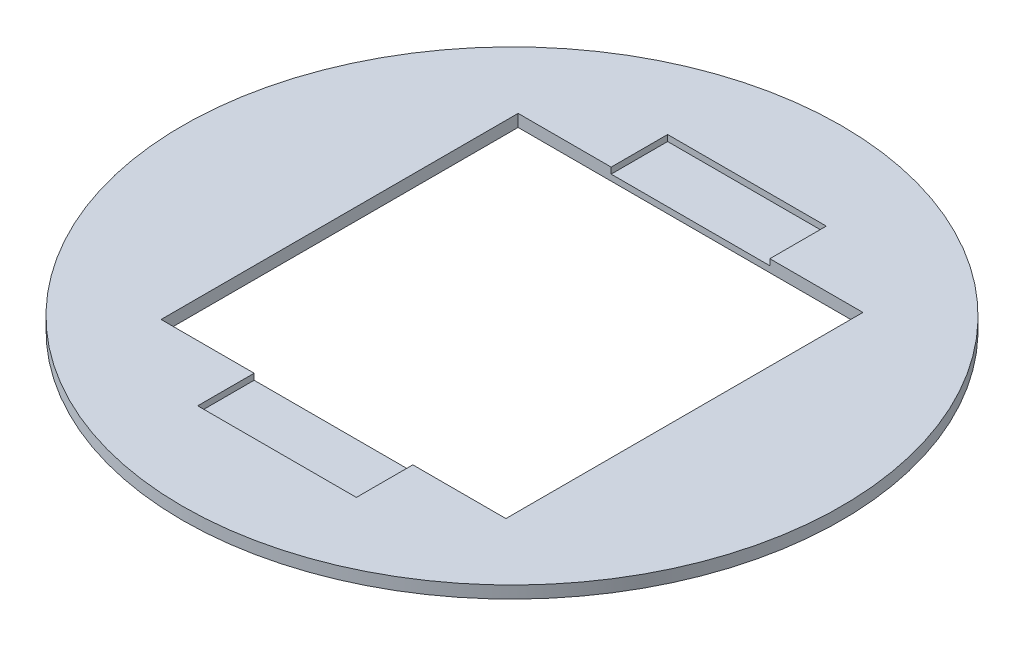
from build123d import *

# Parameters (mm, degrees)
SKETCH1_R           = 54
BOSS_EXTRUDE1_DEPTH = 2
SKETCH2_W           = 56.5
SKETCH2_H           = 58.5
CUT_EXTRUDE1_DEPTH  = 2
SKETCH3_W           = 26
SKETCH3_H           = 9.25
CUT_EXTRUDE2_DEPTH  = 1


with BuildPart() as part:
    # Sketch1 → Boss-Extrude1 (new body)
    with BuildSketch(Plane(origin=(0, 0, 0), x_dir=(1, 0, 0), z_dir=(0, 1, 0))):
        Circle(SKETCH1_R)
    extrude(amount=BOSS_EXTRUDE1_DEPTH)

    # Sketch2 → Cut-Extrude1 (cut)
    with BuildSketch(Plane(origin=(0, 2, 0), x_dir=(1, 0, 0), z_dir=(0, 1, 0))):
        Rectangle(SKETCH2_W, SKETCH2_H)
    extrude(amount=-CUT_EXTRUDE1_DEPTH, mode=Mode.SUBTRACT)

    # Sketch3 → Cut-Extrude2 (cut)
    with BuildSketch(Plane(origin=(0, 2, 0), x_dir=(1, 0, 0), z_dir=(0, 1, 0))):
        with Locations((0, 33.875)):
            Rectangle(SKETCH3_W, SKETCH3_H)
        with Locations((0, -33.875)):
            Rectangle(SKETCH3_W, SKETCH3_H)
    extrude(amount=-CUT_EXTRUDE2_DEPTH, mode=Mode.SUBTRACT)


solid = part.part
